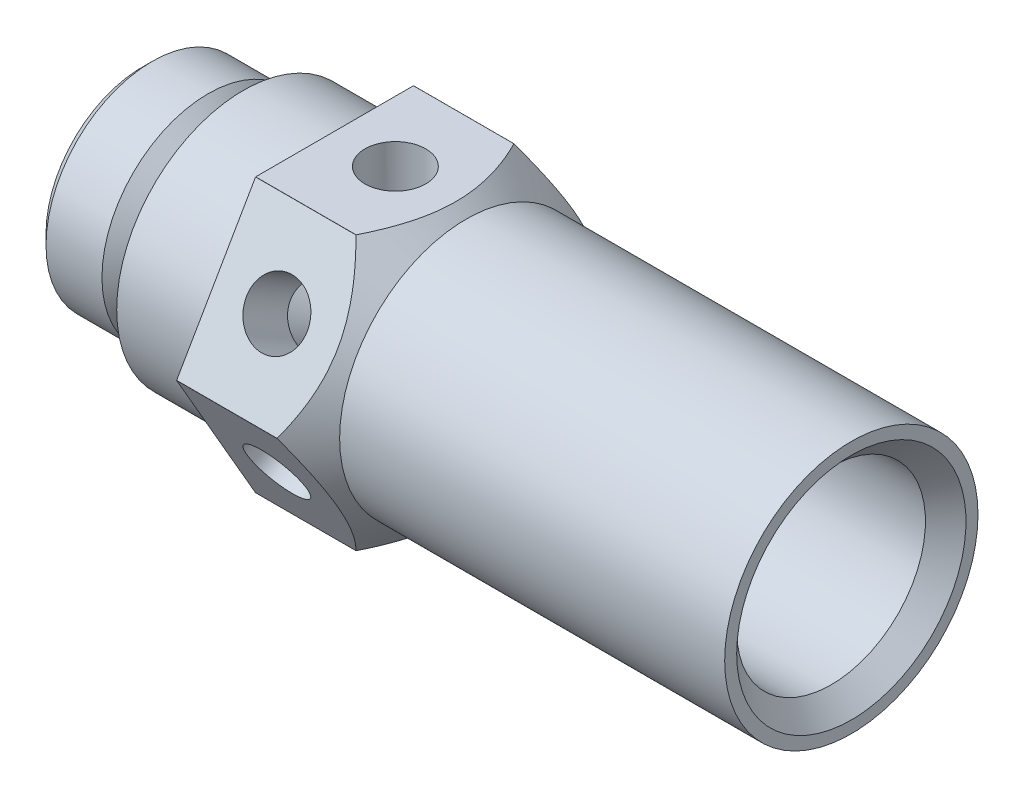
from build123d import *

# Parameters (mm, degrees)
WYTNIJ_WYCI_GNI_CIE1_START = -52
WYTNIJ_WYCI_GNI_CIE1_DEPTH = 72
SZKIC3_R                   = 3
WYTNIJ_WYCI_GNI_CIE2_DEPTH = 12
SZYK_KO_OWY1_COUNT         = 6


with BuildPart() as part:
    # Szkic1 → Obrót1 (revolve)
    with BuildSketch(Plane.XY):
        Polygon((0, -4), (0, -9.4775), (1, -10.4775), (6.5225, -10.4775), (8, -9), (10, -9), (10, -11.1), (10.489897949, -11.5), (10, -12.1), (10, -12.5), (19, -12.5), (19, -15.585), (28.915, -15.585), (32, -12.5), (70, -12.5), (70, -11.3155), (68, -9.3155), (54, -9.3155), (53, -10.5), (50, -10.5), (50, -8.5), (19, -8.5), (19, -8.1), (22, -5), (19, -5), (19, -4), align=None)
    revolve(axis=Axis((0, 0, 0), (1, 0, 0)))

    # Szkic2 → Wytnij-wyciągnięcie1 (cut)
    with BuildSketch(Plane.ZY.offset(-19).offset(WYTNIJ_WYCI_GNI_CIE1_START)):
        Polygon((-92.411763114, 13.5), (-7.787311795, 13.5), (7.787311795, 13.5), (92.411763114, 13.5), (92.411763114, 182.748902638), (-92.411763114, 182.748902638), align=None)
    wytnij_wyci_gni_cie1 = extrude(amount=WYTNIJ_WYCI_GNI_CIE1_DEPTH, mode=Mode.SUBTRACT)

    # Szkic3 → Wytnij-wyciągnięcie2 (cut)
    with BuildSketch(Plane(origin=(0, 13.5, 0), x_dir=(1, 0, 0), z_dir=(0, 1, 0))):
        with Locations((25, 0)):
            Circle(SZKIC3_R)
    wytnij_wyci_gni_cie2 = extrude(amount=-WYTNIJ_WYCI_GNI_CIE2_DEPTH, mode=Mode.SUBTRACT)

    # Szyk kołowy1: Wytnij-wyciągnięcie1, Wytnij-wyciągnięcie2 ×6 about axis
    szyk_ko_owy1_axis = Axis((0, 0, 0), (-1, 0, 0))
    for i in range(1, SZYK_KO_OWY1_COUNT):
        add(wytnij_wyci_gni_cie1.rotate(szyk_ko_owy1_axis, i * 360 / SZYK_KO_OWY1_COUNT), mode=Mode.SUBTRACT)
        add(wytnij_wyci_gni_cie2.rotate(szyk_ko_owy1_axis, i * 360 / SZYK_KO_OWY1_COUNT), mode=Mode.SUBTRACT)


solid = part.part
